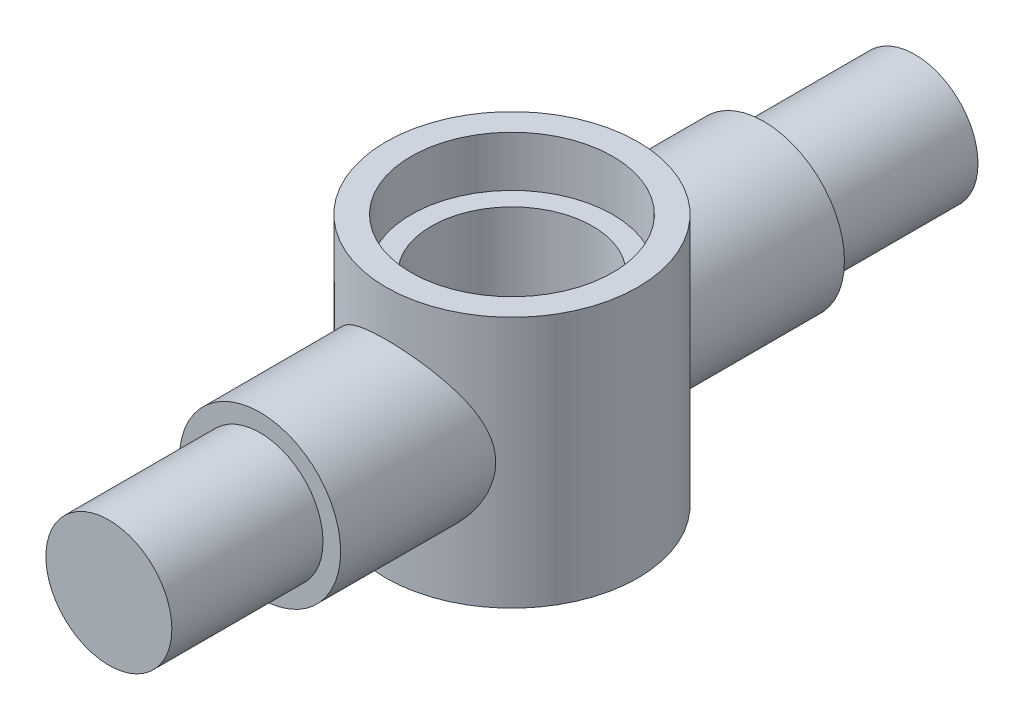
from build123d import *

# Parameters (mm, degrees)
SKETCH2_R                = 25
BOSS_EXTRUDE1_DEPTH      = 50
SKETCH3_R                = 16
BOSS_EXTRUDE2_DEPTH      = 50
SKETCH4_R                = 12.5
BOSS_EXTRUDE3_DEPTH      = 30
BOSS_EXTRUDE3_DEPTH_BACK = 130


with BuildPart() as part:
    # Sketch2 → Boss-Extrude1 (new body)
    with BuildSketch(Plane(origin=(0, 0, 0), x_dir=(1, 0, 0), z_dir=(0, 1, 0))):
        Circle(SKETCH2_R)
    extrude(amount=BOSS_EXTRUDE1_DEPTH)

    # Sketch3 → Boss-Extrude2 (add, symmetric)
    with BuildSketch(Plane.XY):
        with Locations((0, 25)):
            Circle(SKETCH3_R)
    extrude(amount=BOSS_EXTRUDE2_DEPTH, both=True)

    # Sketch4 → Boss-Extrude3 (add, two sides)
    with BuildSketch(Plane.XY.offset(50)) as boss_extrude3_sk:
        with Locations((0, 25)):
            Circle(SKETCH4_R)
    extrude(amount=BOSS_EXTRUDE3_DEPTH)
    extrude(boss_extrude3_sk.sketch, amount=-BOSS_EXTRUDE3_DEPTH_BACK)

    # Sketch5 → Cut-Revolve1 (revolve, cut)
    with BuildSketch(Plane.XY):
        Polygon((0, 50), (0, 0), (16, 0), (16, 40), (20, 40), (20, 50), align=None)
    revolve(axis=Axis((0, 55, 0), (0, -1, 0)), mode=Mode.SUBTRACT)


solid = part.part
